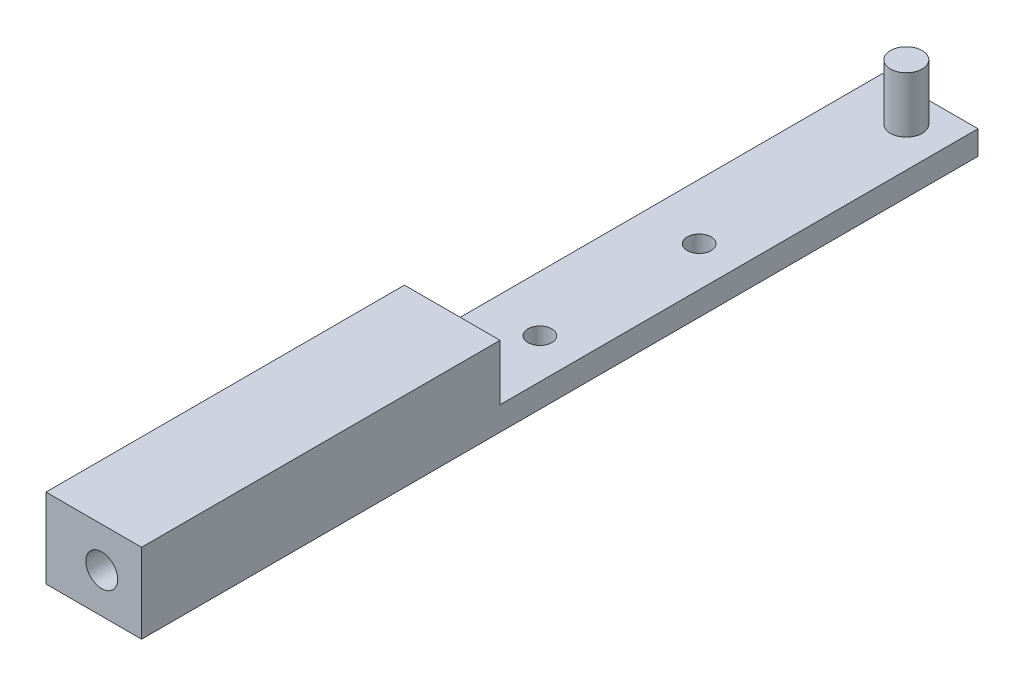
from build123d import *

# Parameters (mm, degrees)
SKETCH1_W               = 10
SKETCH1_H               = 105
BOSS_EXTRUDE1_DEPTH     = 10
SKETCH2_W               = 60
SKETCH2_H               = 13.095712102
CUT_EXTRUDE1_DEPTH      = 10
CUT_EXTRUDE1_DEPTH_BACK = 10
SKETCH3_R               = 2
BOSS_EXTRUDE2_DEPTH     = 7
SKETCH4_R               = 1.5
CUT_EXTRUDE2_DEPTH      = 14
SKETCH5_R               = 2
CUT_EXTRUDE3_DEPTH      = 10
BOSS_EXTRUDE3_DEPTH     = 2


with BuildPart() as part:
    # Sketch1 → Boss-Extrude1 (new body)
    with BuildSketch(Plane(origin=(0, 0, 0), x_dir=(1, 0, 0), z_dir=(0, 1, 0))):
        Rectangle(SKETCH1_W, SKETCH1_H)
    extrude(amount=BOSS_EXTRUDE1_DEPTH)

    # Sketch2 → Cut-Extrude1 (cut, two sides)
    with BuildSketch(Plane(origin=(0, 0, 0), x_dir=(0, 0, -1), z_dir=(1, 0, 0))) as cut_extrude1_sk:
        with Locations((22.5, 9.547856051)):
            Rectangle(SKETCH2_W, SKETCH2_H)
    extrude(amount=CUT_EXTRUDE1_DEPTH, mode=Mode.SUBTRACT)
    extrude(cut_extrude1_sk.sketch, amount=-CUT_EXTRUDE1_DEPTH_BACK, mode=Mode.SUBTRACT)

    # Sketch3 → Boss-Extrude2 (add)
    with BuildSketch(Plane(origin=(0, 3, 0), x_dir=(1, 0, 0), z_dir=(0, 1, 0))):
        with Locations((0, 48.5)):
            Circle(SKETCH3_R)
    extrude(amount=BOSS_EXTRUDE2_DEPTH)

    # Sketch4 → Cut-Extrude2 (cut)
    with BuildSketch(Plane(origin=(0, 0, 0), x_dir=(1, 0, 0), z_dir=(0, 1, 0))):
        with Locations((0, 2.5)):
            Circle(SKETCH4_R)
        with Locations((0, 22.5)):
            Circle(SKETCH4_R)
    extrude(amount=CUT_EXTRUDE2_DEPTH, mode=Mode.SUBTRACT)

    # Sketch5 → Cut-Extrude3 (cut)
    with BuildSketch(Plane.XY.offset(52.5)):
        with Locations((0, 5)):
            Circle(SKETCH5_R)
    extrude(amount=-CUT_EXTRUDE3_DEPTH, mode=Mode.SUBTRACT)

    # Sketch6 → Boss-Extrude3 (add)
    with BuildSketch(Plane.ZY.offset(5)):
        Polygon((7.5, 10), (52.5, 10), (52.5, 0), (-52.5, 0), (-52.5, 3), (7.5, 3), align=None)
    extrude(amount=BOSS_EXTRUDE3_DEPTH)


solid = part.part
